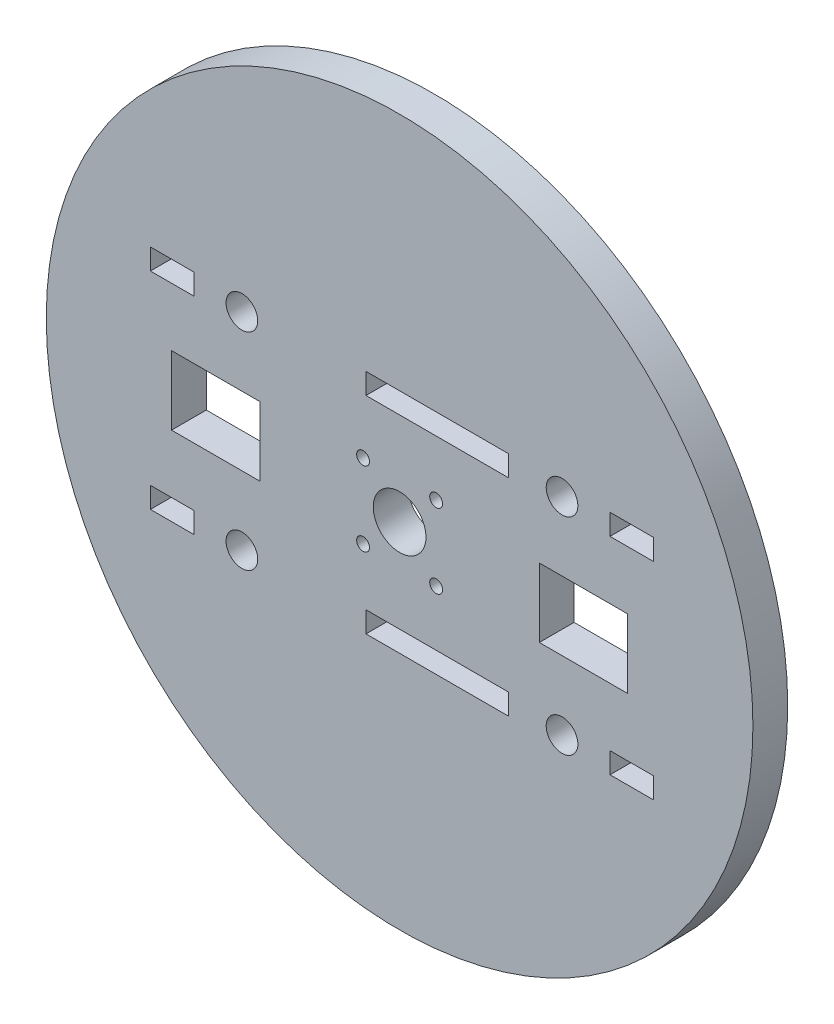
from build123d import *

# Parameters (mm, degrees)
SKETCH3_R           = 50.7685
SKETCH3_R_2         = 3.785
SKETCH3_R_3         = 0.925
SKETCH3_R_4         = 2.275
SKETCH3_W           = 12.7001
SKETCH3_H           = 9.9
SKETCH3_W_2         = 6.25
SKETCH3_H_2         = 3
SKETCH3_W_3         = 20.5
BOSS_EXTRUDE7_DEPTH = 5


with BuildPart() as part:
    # Sketch3 → Boss-Extrude7 (new body)
    with BuildSketch(Plane.XY):
        with Locations((60.71181161, 107.410494733)):
            Circle(SKETCH3_R)
        with Locations((60.71181161, 107.410494733)):
            Circle(SKETCH3_R_2, mode=Mode.SUBTRACT)
        with Locations((65.96181161, 102.060494733)):
            Circle(SKETCH3_R_3, mode=Mode.SUBTRACT)
        with Locations((38.0489, 92.578417091)):
            Circle(SKETCH3_R_4, mode=Mode.SUBTRACT)
        with Locations((84.0509, 92.578417091)):
            Circle(SKETCH3_R_4, mode=Mode.SUBTRACT)
        with Locations((84.0509, 122.242572375)):
            Circle(SKETCH3_R_4, mode=Mode.SUBTRACT)
        with Locations((38.0489, 122.242572375)):
            Circle(SKETCH3_R_4, mode=Mode.SUBTRACT)
        with Locations((55.46181161, 102.060494733)):
            Circle(SKETCH3_R_3, mode=Mode.SUBTRACT)
        with Locations((65.96181161, 112.760494733)):
            Circle(SKETCH3_R_3, mode=Mode.SUBTRACT)
        with Locations((55.46181161, 112.760494733)):
            Circle(SKETCH3_R_3, mode=Mode.SUBTRACT)
        with Locations((34.28955, 107.410494733)):
            Rectangle(SKETCH3_W, SKETCH3_H, mode=Mode.SUBTRACT)
        with Locations((28.0289, 92.578417091)):
            Rectangle(SKETCH3_W_2, SKETCH3_H_2, mode=Mode.SUBTRACT)
        with Locations((66.1289, 92.578417091)):
            Rectangle(SKETCH3_W_3, SKETCH3_H_2, mode=Mode.SUBTRACT)
        with Locations((94.0689, 92.578417091)):
            Rectangle(SKETCH3_W_2, SKETCH3_H_2, mode=Mode.SUBTRACT)
        with Locations((28.0289, 122.242572375)):
            Rectangle(SKETCH3_W_2, SKETCH3_H_2, mode=Mode.SUBTRACT)
        with Locations((66.1289, 122.242572375)):
            Rectangle(SKETCH3_W_3, SKETCH3_H_2, mode=Mode.SUBTRACT)
        with Locations((94.0689, 122.242572375)):
            Rectangle(SKETCH3_W_2, SKETCH3_H_2, mode=Mode.SUBTRACT)
        with Locations((87.13407322, 107.410494733)):
            Rectangle(SKETCH3_W, SKETCH3_H, mode=Mode.SUBTRACT)
    extrude(amount=BOSS_EXTRUDE7_DEPTH)


solid = part.part
